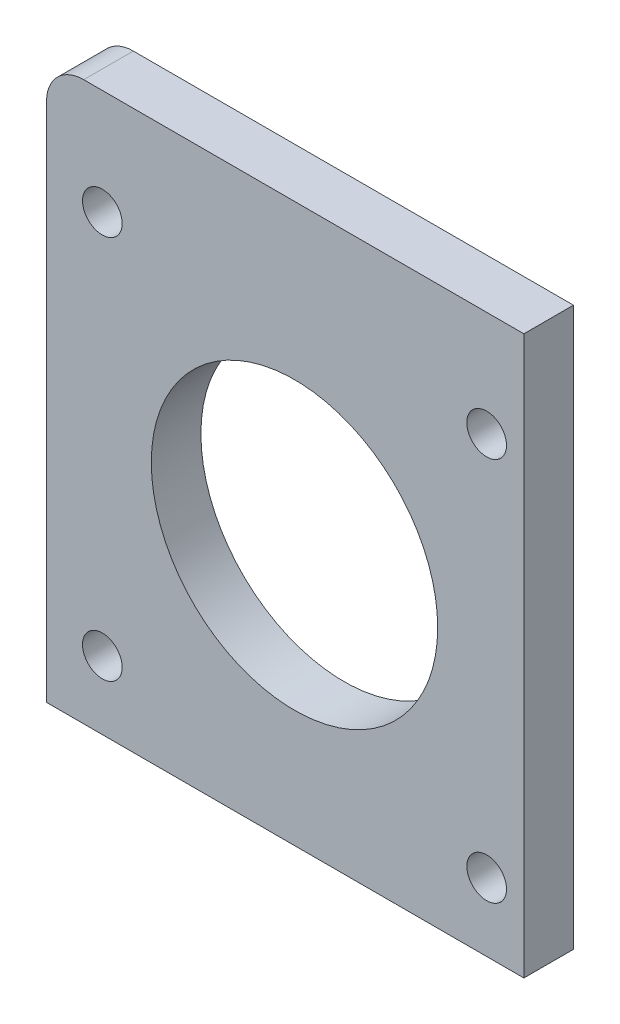
from build123d import *

# Parameters (mm, degrees)
SKETCH1_R           = 1.6
SKETCH1_R_2         = 3
BOSS_EXTRUDE1_DEPTH = 4
SKETCH2_R           = 11.550203763
CUT_EXTRUDE1_DEPTH  = 5


with BuildPart() as part:
    # Sketch1 → Boss-Extrude1 (new body)
    with BuildSketch(Plane.XY):
        with BuildLine():
            Line((27.071068699, -55.594908829), (62.571068699, -55.594908829))
            Line((62.571068699, -55.594908829), (62.571068699, -100.594908829))
            Line((62.571068699, -100.594908829), (24.071068699, -100.594908829))
            Line((24.071068699, -100.594908829), (24.071068699, -58.594908829))
            ThreePointArc((24.071068699, -58.594908829), (24.949748355, -56.473588486), (27.071068699, -55.594908829))
        make_face()
        with Locations((28.571068699, -64.094908829)):
            Circle(SKETCH1_R, mode=Mode.SUBTRACT)
        with Locations((44.071068699, -79.594908829)):
            Circle(SKETCH1_R_2, mode=Mode.SUBTRACT)
        with Locations((59.571068699, -64.094908829)):
            Circle(SKETCH1_R, mode=Mode.SUBTRACT)
        with Locations((28.571068699, -95.094908829)):
            Circle(SKETCH1_R, mode=Mode.SUBTRACT)
        with Locations((59.571068699, -95.094908829)):
            Circle(SKETCH1_R, mode=Mode.SUBTRACT)
    extrude(amount=BOSS_EXTRUDE1_DEPTH)

    # Sketch2 → Cut-Extrude1 (cut)
    with BuildSketch(Plane(origin=(0, 0, 0), x_dir=(-1, 0, 0), z_dir=(0, 0, -1))):
        with Locations((-44.071068699, -79.594908829)):
            Circle(SKETCH2_R)
    extrude(amount=-CUT_EXTRUDE1_DEPTH, mode=Mode.SUBTRACT)


solid = part.part
